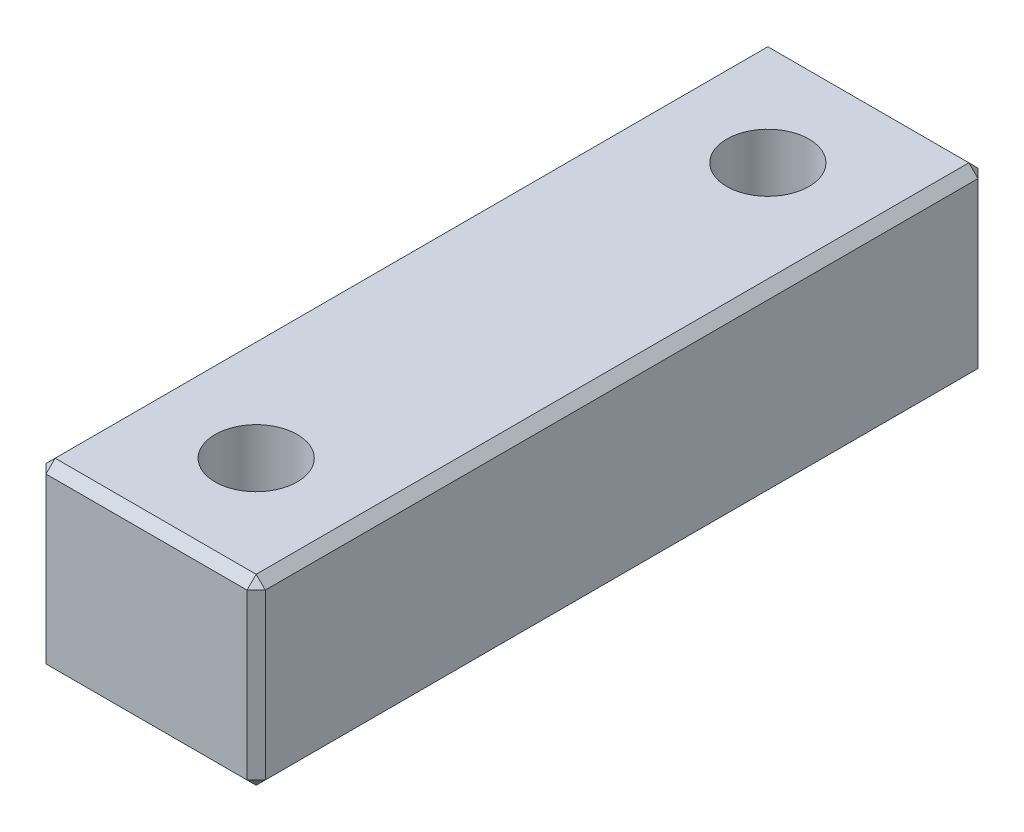
from build123d import *

# Parameters (mm, degrees)
CROQUIS1_W              = 12
CROQUIS1_H              = 10
SALIENTE_EXTRUIR1_DEPTH = 20
CHAFL_N1_SIZE           = 0.5


with BuildPart() as part:
    # Croquis1 → Saliente-Extruir1 (new body, symmetric)
    with BuildSketch(Plane.XY):
        Rectangle(CROQUIS1_W, CROQUIS1_H)
    extrude(amount=SALIENTE_EXTRUIR1_DEPTH, both=True)

    # Croquis3 → Cortar-Revolución1 (revolve, cut)
    with BuildSketch(Plane.XY.offset(-14)):
        Polygon((0, 5), (-2.25, 5), (-2.25, -3.2), (-4, -5), (0, -5), align=None)
    cortar_revoluci_n1 = revolve(axis=Axis((0, 5, -14), (0, -1, 0)), mode=Mode.SUBTRACT)

    # Simetría1: Cortar-Revolución1 across plane
    add(cortar_revoluci_n1.mirror(Plane.XY), mode=Mode.SUBTRACT)

    # Chaflán1
    chafl_n1_edges = [part.edges().sort_by_distance(p)[0] for p in [
        (6, 0, 20),
        (0, 5, 20),
        (-6, 0, 20),
        (0, 5, -20),
        (6, 0, -20),
        (0, -5, -20),
        (-6, 0, -20),
        (0, -5, 20),
        (-6, 5, 0),
        (6, 5, 0),
        (6, -5, 0),
        (-6, -5, 0),
    ]]
    chamfer(chafl_n1_edges, length=CHAFL_N1_SIZE)


solid = part.part
